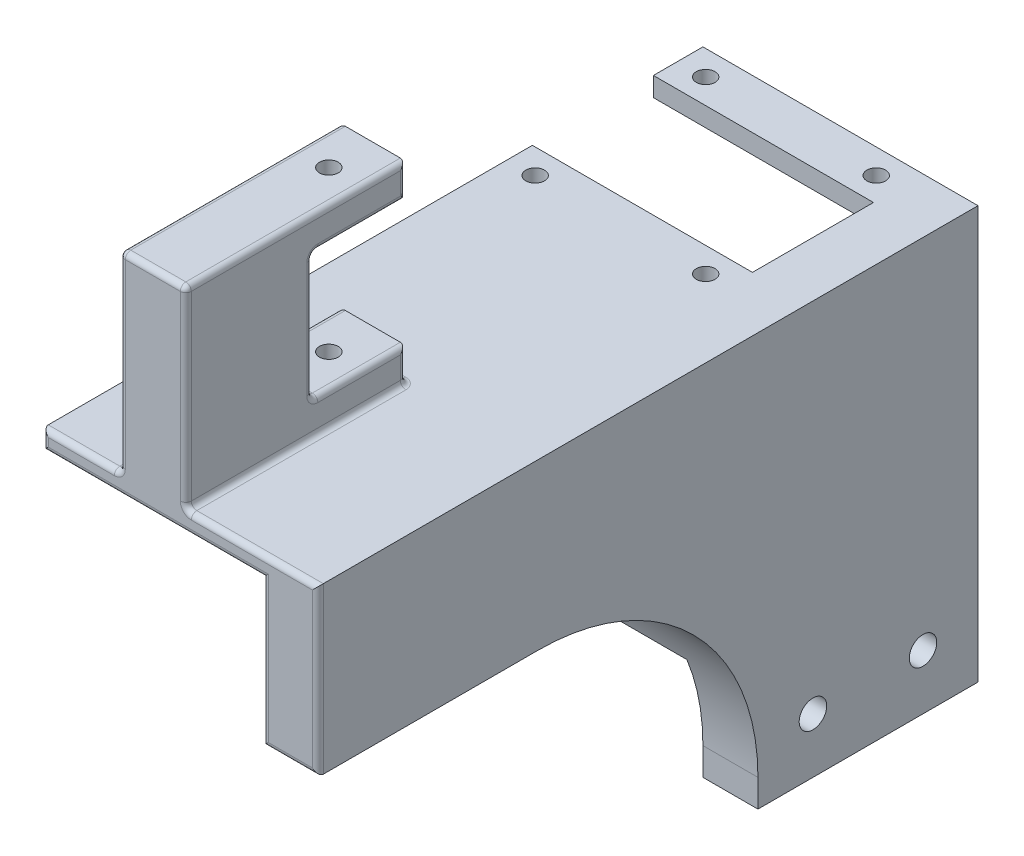
from build123d import *

# Parameters (mm, degrees)
SKETCH1_W               = 40
SKETCH1_H               = 55
SKETCH1_H_2             = 20
SKETCH1_R               = 2.5
BOSS_EXTRUDE1_DEPTH     = 10
SKETCH3_W               = 40
SKETCH3_H               = 10
BOSS_EXTRUDE2_DEPTH     = 40
SKETCH4_W               = 9
SKETCH4_H               = 3.5
BOSS_EXTRUDE3_DEPTH     = 40
SKETCH5_R               = 1.7
CUT_EXTRUDE1_DEPTH      = 3.5
SKETCH7_W               = 40
SKETCH7_H               = 3.5
BOSS_EXTRUDE4_DEPTH     = 80
SKETCH8_W               = 12
SKETCH8_H               = 40
BOSS_EXTRUDE5_DEPTH     = 35
SKETCH9_W               = 12
SKETCH9_H               = 23
CUT_EXTRUDE2_DEPTH      = 17
SKETCH10_R              = 1.7
CUT_EXTRUDE3_DEPTH      = 1
CUT_EXTRUDE3_DEPTH_BACK = 38.5
FILLET1_R               = 1
FILLET2_R               = 40


with BuildPart() as part:
    # Sketch1 → Boss-Extrude1 (new body)
    with BuildSketch(Plane(origin=(0, 0, 0), x_dir=(0, 0, -1), z_dir=(1, 0, 0))):
        with Locations((0, 27.5)):
            Rectangle(SKETCH1_W, SKETCH1_H)
        with Locations((0, -10)):
            Rectangle(SKETCH1_W, SKETCH1_H_2)
        with Locations((10, -10)):
            Circle(SKETCH1_R, mode=Mode.SUBTRACT)
        with Locations((-10, -10)):
            Circle(SKETCH1_R, mode=Mode.SUBTRACT)
    extrude(amount=BOSS_EXTRUDE1_DEPTH)

    # Sketch3 → Boss-Extrude2 (add)
    with BuildSketch(Plane.ZY):
        with Locations((0, 5)):
            Rectangle(SKETCH3_W, SKETCH3_H)
    extrude(amount=BOSS_EXTRUDE2_DEPTH)

    # Sketch4 → Boss-Extrude3 (add)
    with BuildSketch(Plane.ZY):
        with Locations((-15.5, 53.25)):
            Rectangle(SKETCH4_W, SKETCH4_H)
    boss_extrude3 = extrude(amount=BOSS_EXTRUDE3_DEPTH)

    # Sketch5 → Cut-Extrude1 (cut)
    with BuildSketch(Plane(origin=(0, 55, 0), x_dir=(1, 0, 0), z_dir=(0, 1, 0))):
        with Locations((-35, 15.5)):
            Circle(SKETCH5_R)
        with Locations((-4, 15.5)):
            Circle(SKETCH5_R)
    cut_extrude1 = extrude(amount=-CUT_EXTRUDE1_DEPTH, mode=Mode.SUBTRACT)

    # Mirror2: Boss-Extrude3, Cut-Extrude1 across plane
    add(boss_extrude3.mirror(Plane.XY))
    add(cut_extrude1.mirror(Plane.XY), mode=Mode.SUBTRACT)

    # Sketch7 → Boss-Extrude4 (add)
    with BuildSketch(Plane.XY.offset(20)):
        with Locations((-20, 53.25)):
            Rectangle(SKETCH7_W, SKETCH7_H)
        Polygon((10, 55), (0, 55), (0, 51.5), (0, 25), (10, 25), align=None)
    extrude(amount=BOSS_EXTRUDE4_DEPTH)

    # Sketch8 → Boss-Extrude5 (add)
    with BuildSketch(Plane(origin=(0, 55, 0), x_dir=(1, 0, 0), z_dir=(0, 1, 0))):
        with Locations((-20, -80)):
            Rectangle(SKETCH8_W, SKETCH8_H)
    extrude(amount=BOSS_EXTRUDE5_DEPTH)

    # Sketch9 → Cut-Extrude2 (cut)
    with BuildSketch(Plane(origin=(0, 0, 60), x_dir=(-1, 0, 0), z_dir=(0, 0, -1))):
        with Locations((20, 72.5)):
            Rectangle(SKETCH9_W, SKETCH9_H)
    extrude(amount=-CUT_EXTRUDE2_DEPTH, mode=Mode.SUBTRACT)

    # Sketch10 → Cut-Extrude3 (cut, two sides)
    with BuildSketch(Plane(origin=(0, 90, 0), x_dir=(1, 0, 0), z_dir=(0, 1, 0))) as cut_extrude3_sk:
        with Locations((-20, -68)):
            Circle(SKETCH10_R)
    extrude(amount=CUT_EXTRUDE3_DEPTH, mode=Mode.SUBTRACT)
    extrude(cut_extrude3_sk.sketch, amount=-CUT_EXTRUDE3_DEPTH_BACK, mode=Mode.SUBTRACT)

    # Fillet1
    fillet1_edges = [part.edges().sort_by_distance(p)[0] for p in [
        (-33, 55, 100),
        (-26, 55, 80),
        (-26, 87, 60),
        (-26, 72.5, 100),
        (-14, 55, 80),
        (-14, 72.5, 100),
        (-20, 55, 60),
        (-14, 87, 60),
        (-26, 90, 80),
        (-20, 90, 100),
        (-14, 90, 80),
        (-26, 58, 60),
        (-14, 58, 60),
        (-14, 72.5, 77),
        (-14, 61, 68.5),
        (-20, 84, 77),
        (-14, 84, 68.5),
        (-26, 72.5, 77),
        (-26, 84, 68.5),
        (-20, 61, 77),
        (-26, 61, 68.5),
        (-20, 51.5, 100),
        (0, 38.25, 100),
        (5, 25, 100),
        (10, 40, 100),
        (-2, 55, 100),
        (-40, 53.25, 100),
    ]]
    fillet(fillet1_edges, radius=FILLET1_R)

    # Fillet2
    fillet2_edges = [part.edges().sort_by_distance(p)[0] for p in [
        (5, 25, 20),
    ]]
    fillet(fillet2_edges, radius=FILLET2_R)


solid = part.part
